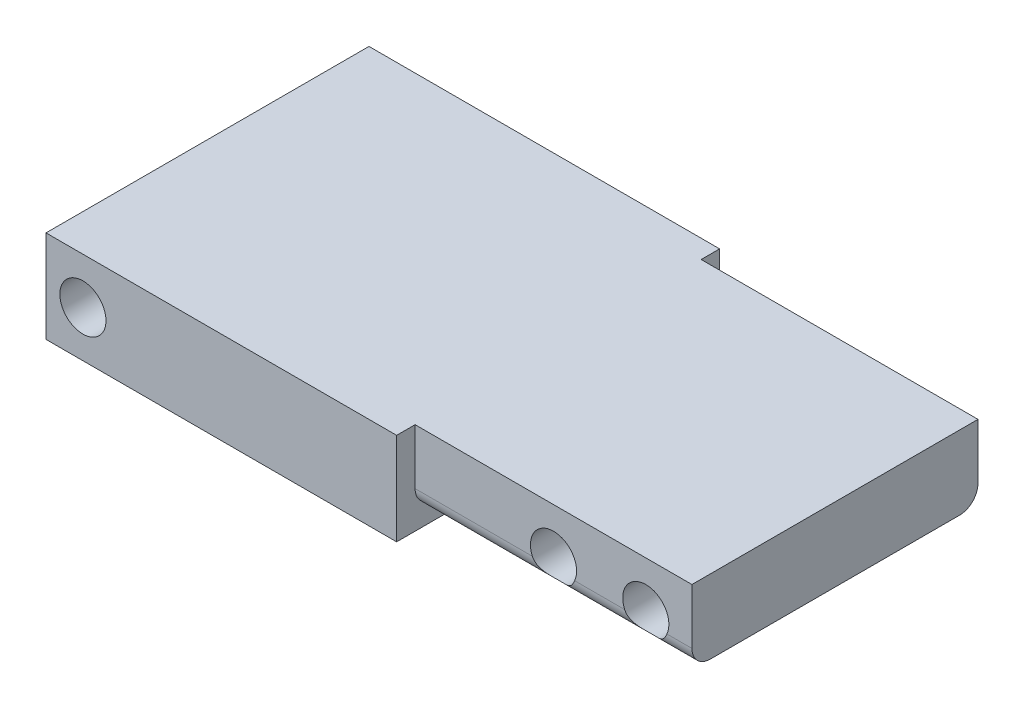
from build123d import *

# Parameters (mm, degrees)
SKETCH1_W      = 35
SKETCH1_H      = 10
EXTRUDE1_DEPTH = 38
SKETCH2_W      = 31
SKETCH2_H      = 8
EXTRUDE2_DEPTH = 30
FILLET1_R      = 2
SKETCH3_R      = 2.5
EXTRUDE3_DEPTH = 34
SKETCH4_R      = 2.5
EXTRUDE4_DEPTH = 36


with BuildPart() as part:
    # Sketch1 → Extrude1 (new body)
    with BuildSketch(Plane(origin=(0, 0, 0), x_dir=(0, 0, -1), z_dir=(1, 0, 0))):
        with Locations((-56.771768295, 48.134111791)):
            Rectangle(SKETCH1_W, SKETCH1_H)
    extrude(amount=EXTRUDE1_DEPTH)

    # Sketch2 → Extrude2 (add)
    with BuildSketch(Plane(origin=(38, 0, 0), x_dir=(0, 0, -1), z_dir=(1, 0, 0))):
        with Locations((-56.771768295, 49.134111791)):
            Rectangle(SKETCH2_W, SKETCH2_H)
    extrude(amount=EXTRUDE2_DEPTH)

    # Fillet1
    fillet1_edges = [part.edges().sort_by_distance(p)[0] for p in [
        (53, 45.134111791, 72.271768295),
        (53, 45.134111791, 41.271768295),
    ]]
    fillet(fillet1_edges, radius=FILLET1_R)

    # Sketch3 → Extrude3 (cut, through all)
    with BuildSketch(Plane(origin=(0, 0, 41.271768295), x_dir=(-1, 0, 0), z_dir=(0, 0, -1))):
        with Locations((-63, 48.134111791)):
            Circle(SKETCH3_R)
        with Locations((-53, 48.134111791)):
            Circle(SKETCH3_R)
    extrude(amount=-EXTRUDE3_DEPTH, mode=Mode.SUBTRACT)

    # Sketch4 → Extrude4 (cut, through all)
    with BuildSketch(Plane(origin=(0, 0, 39.271768295), x_dir=(-1, 0, 0), z_dir=(0, 0, -1))):
        with Locations((-4, 48.134111791)):
            Circle(SKETCH4_R)
    extrude(amount=-EXTRUDE4_DEPTH, mode=Mode.SUBTRACT)


solid = part.part
